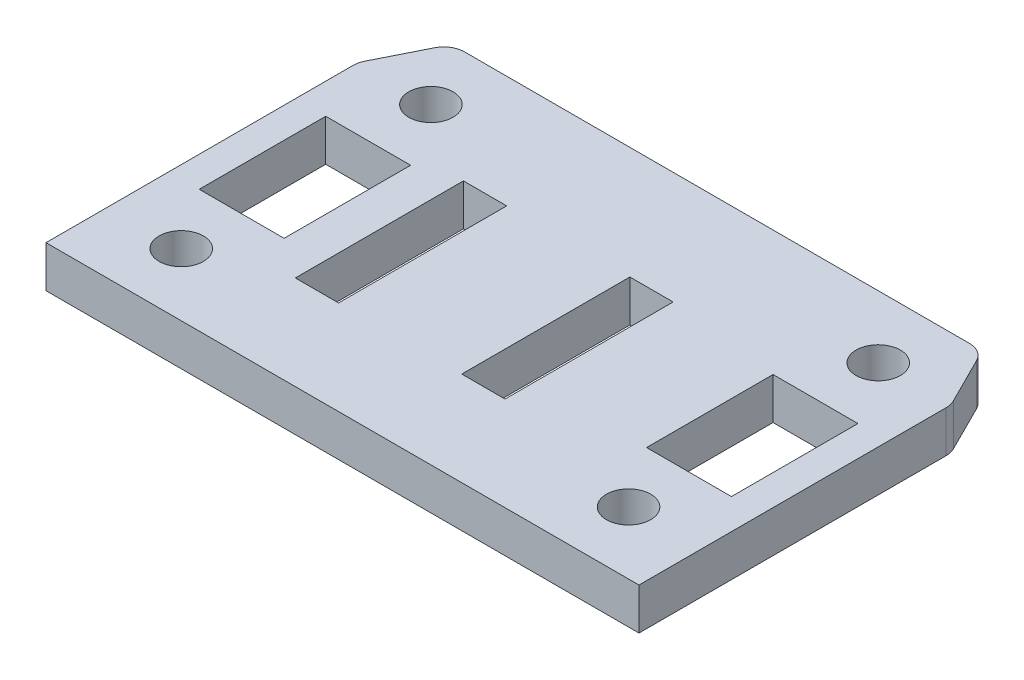
from build123d import *

# Parameters (mm, degrees)
SKETCH1_W               = 80.9625
SKETCH1_H               = 57.15
BOSS_EXTRUDE1_DEPTH     = 6.35
SKETCH2_W               = 6.604
SKETCH2_H               = 25.654
CUT_EXTRUDE1_DEPTH      = 7.35
F_1_4_CLEARANCE_HOLE1_D = 6.7564
SKETCH5_W               = 4.7625
SKETCH5_H               = 47.625
BOSS_EXTRUDE3_DEPTH     = 6.35
FILLET1_R               = 3.175
SKETCH6_W               = 12.954
SKETCH6_H               = 19.304
CUT_EXTRUDE2_DEPTH      = 7.35


with BuildPart() as part:
    # Sketch1 → Boss-Extrude1 (new body)
    with BuildSketch(Plane(origin=(0, 0, 0), x_dir=(1, 0, 0), z_dir=(0, 1, 0))):
        Rectangle(SKETCH1_W, SKETCH1_H)
    extrude(amount=BOSS_EXTRUDE1_DEPTH)

    # Sketch2 → Cut-Extrude1 (cut, through all)
    with BuildSketch(Plane(origin=(0, 0, 0), x_dir=(-1, 0, 0), z_dir=(0, -1, 0))):
        with Locations((-7.14375, -1.389678771)):
            Rectangle(SKETCH2_W, SKETCH2_H)
        with Locations((18.25625, -1.389678771)):
            Rectangle(SKETCH2_W, SKETCH2_H)
    extrude(amount=-CUT_EXTRUDE1_DEPTH, mode=Mode.SUBTRACT)

    # 1/4 Clearance Hole1 (through all)
    with Locations(Plane(origin=(0, 6.35, 0), x_dir=(1, 0, 0), z_dir=(0, 1, 0))):
        with Locations((-34.13125, 19.05), (-34.13125, -19.05), (34.13125, -19.05), (34.13125, 19.05)):
            Hole(F_1_4_CLEARANCE_HOLE1_D / 2)

    # Sketch5 → Boss-Extrude3 (add)
    with BuildSketch(Plane(origin=(0, 6.35, 0), x_dir=(1, 0, 0), z_dir=(0, 1, 0))):
        with Locations((42.8625, -4.7625)):
            Rectangle(SKETCH5_W, SKETCH5_H)
        Polygon((40.48125, 28.575), (40.48125, 19.05), (45.24375, 19.05), align=None)
        with Locations((-42.8625, -4.7625)):
            Rectangle(SKETCH5_W, SKETCH5_H)
        Polygon((-40.48125, 28.575), (-45.24375, 19.05), (-40.48125, 19.05), align=None)
    extrude(amount=-BOSS_EXTRUDE3_DEPTH)

    # Fillet1
    fillet1_edges = [part.edges().sort_by_distance(p)[0] for p in [
        (-40.48125, 3.175, -28.575),
        (40.48125, 3.175, -28.575),
        (45.24375, 3.175, -19.05),
        (-45.24375, 3.175, -19.05),
    ]]
    fillet(fillet1_edges, radius=FILLET1_R)

    # Sketch6 → Cut-Extrude2 (cut, through all)
    with BuildSketch(Plane(origin=(0, 6.35, 0), x_dir=(1, 0, 0), z_dir=(0, 1, 0))):
        with Locations((-34.13125, -0.176936686)):
            Rectangle(SKETCH6_W, SKETCH6_H)
        with Locations((34.13125, -0.176936686)):
            Rectangle(SKETCH6_W, SKETCH6_H)
    extrude(amount=-CUT_EXTRUDE2_DEPTH, mode=Mode.SUBTRACT)


solid = part.part
